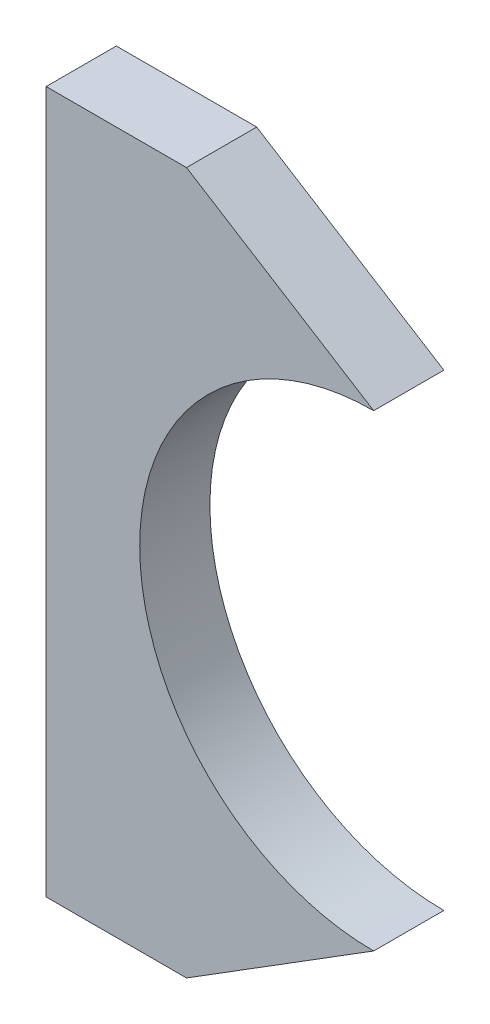
from build123d import *

# Parameters (mm, degrees)
BOSS_EXTRUDE1_DEPTH = 7.5


with BuildPart() as part:
    # Sketch1 → Boss-Extrude1 (new body, symmetric)
    with BuildSketch(Plane.XY):
        with BuildLine():
            Line((-70, 75), (-40, 75))
            Line((-40, 75), (0, 50))
            ThreePointArc((0, 50), (-50, 0), (0, -50))
            Line((0, -50), (-40, -75))
            Line((-40, -75), (-70, -75))
            Line((-70, -75), (-70, 75))
        make_face()
    extrude(amount=BOSS_EXTRUDE1_DEPTH, both=True)


solid = part.part
